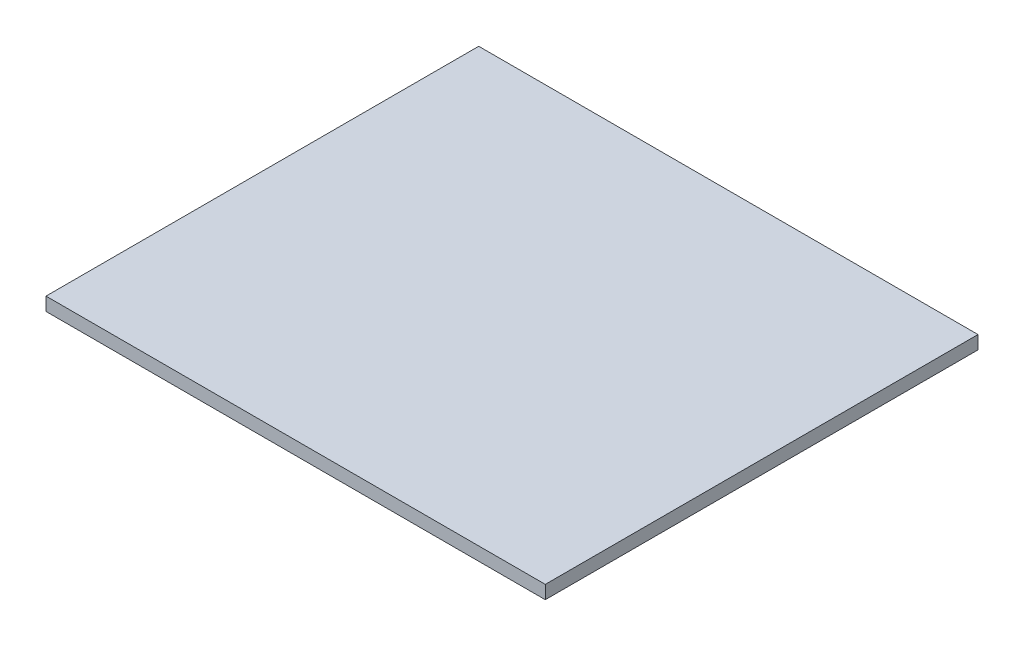
from build123d import *

# Parameters (mm, degrees)
SKETCH1_W           = 15
SKETCH1_H           = 13
BOSS_EXTRUDE1_DEPTH = 0.4


with BuildPart() as part:
    # Sketch1 → Boss-Extrude1 (new body)
    with BuildSketch(Plane(origin=(0, 0, 0), x_dir=(1, 0, 0), z_dir=(0, 1, 0))):
        with Locations((-3.890092811, -1.392857143)):
            Rectangle(SKETCH1_W, SKETCH1_H)
    extrude(amount=BOSS_EXTRUDE1_DEPTH)


solid = part.part
